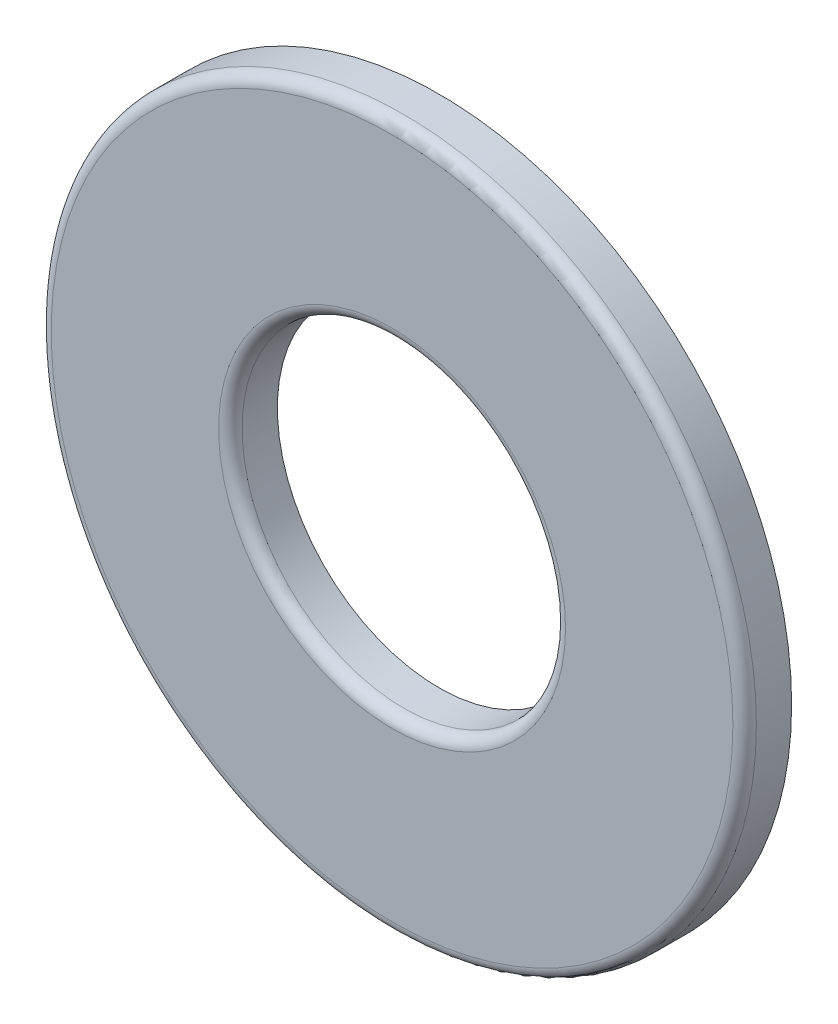
from build123d import *

# Parameters (mm, degrees)
SKETCH3_R                = 9.525
SKETCH3_R_2              = 4.3688
BOSS_EXTRUDE1_DEPTH      = 0.635
BOSS_EXTRUDE1_DEPTH_BACK = 0.635
FILLET1_R                = 0.3175


with BuildPart() as part:
    # Sketch3 → Boss-Extrude1 (new body, two sides)
    with BuildSketch(Plane.XY) as boss_extrude1_sk:
        Circle(SKETCH3_R)
        Circle(SKETCH3_R_2, mode=Mode.SUBTRACT)
    extrude(amount=BOSS_EXTRUDE1_DEPTH)
    extrude(boss_extrude1_sk.sketch, amount=-BOSS_EXTRUDE1_DEPTH_BACK)

    # Fillet1
    fillet1_edges = [part.edges().sort_by_distance(p)[0] for p in [
        (-9.525, 0, 0.635),
        (-4.3688, 0, 0.635),
    ]]
    fillet(fillet1_edges, radius=FILLET1_R)


solid = part.part
